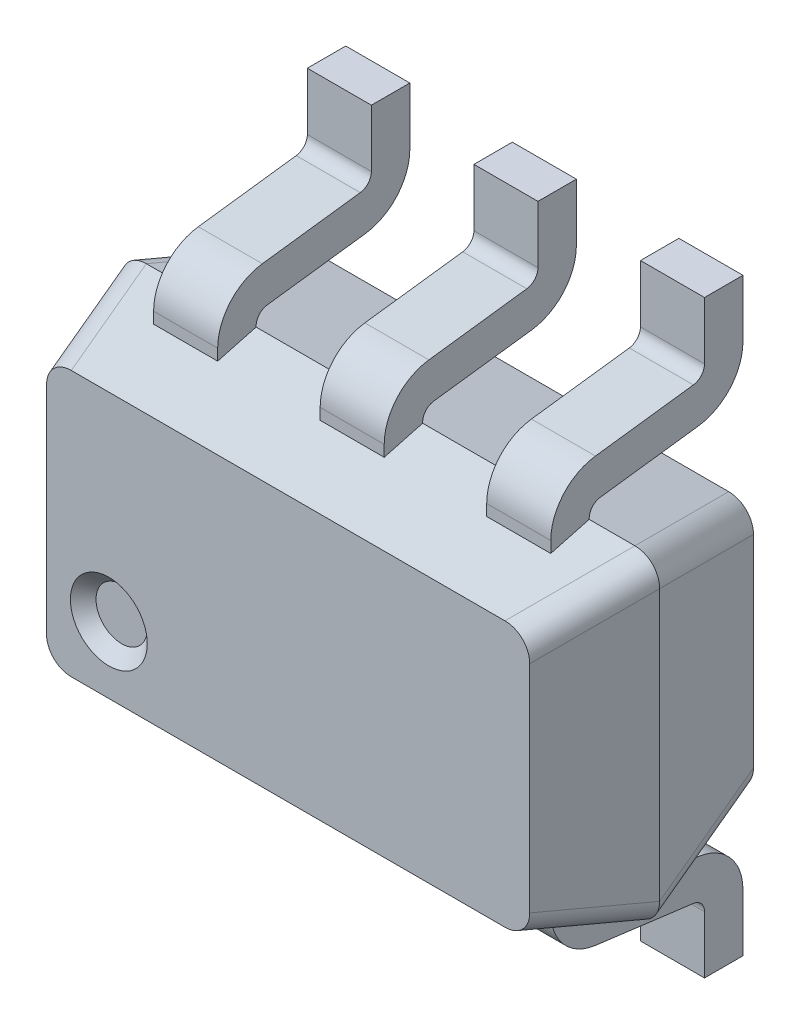
from build123d import *

# Parameters (mm, degrees)
EXTRUDE_START             = 0.6
SKETCH_1_W                = 2.1
SKETCH_1_H                = 1.25
EXTRUDE_1_DEPTH           = 0.4
EXTRUDE_1_TAPER           = 15
EXTRUDE_1_OTHER_WAY_DEPTH = 0.5
EXTRUDE_1_OTHER_WAY_TAPER = 15
EXTRUDE_START_2           = 0.65
EXTRUDE_4_DEPTH           = 0.125
EXTRUDE_5_DEPTH           = 0.125
PATTERN_LINEAR_2_COUNT    = 3
PATTERN_LINEAR_2_PITCH    = 0.65
PATTERN_LINEAR_3_COUNT    = 3
PATTERN_LINEAR_3_PITCH    = 0.65
FILLET_3_R                = 0.1
SKETCH_3_R                = 0.15
CUT_EXTRUDE_6_DEPTH       = 0.05
CUT_EXTRUDE_6_DRAFT       = -45


with BuildPart() as part:
    # Sketch 1 → Extrude 1 (new body)
    with BuildSketch(Plane.XY.offset(EXTRUDE_START)):
        Rectangle(SKETCH_1_W, SKETCH_1_H)
    extrude(amount=EXTRUDE_1_DEPTH, taper=EXTRUDE_1_TAPER)

    # Sketch 1 → Extrude 1 other way (add)
    with BuildSketch(Plane.XY.offset(EXTRUDE_START)):
        Rectangle(SKETCH_1_W, SKETCH_1_H)
    extrude(amount=-EXTRUDE_1_OTHER_WAY_DEPTH, taper=EXTRUDE_1_OTHER_WAY_TAPER)

    # Sketch 2 → Extrude 4 (add, symmetric)
    with BuildSketch(Plane(origin=(0, 0, 0), x_dir=(0, 0, -1), z_dir=(1, 0, 0)).offset(EXTRUDE_START_2)):
        with BuildLine():
            Line((-0.6, 0.55), (-0.75, 0.55))
            Line((-0.75, 0.55), (-0.75, 0.628617172))
            ThreePointArc((-0.75, 0.628617172), (-0.700198025, 0.760679859), (-0.575594468, 0.82697272))
            Line((-0.575594468, 0.82697272), (-0.193601383, 0.876262542))
            ThreePointArc((-0.193601383, 0.876262542), (-0.162450494, 0.892835757), (-0.15, 0.925851429))
            Line((-0.15, 0.925851429), (-0.15, 1.15))
            Line((-0.15, 1.15), (0, 1.15))
            Line((0, 1.15), (0, 0.925851429))
            ThreePointArc((0, 0.925851429), (-0.049801975, 0.793788742), (-0.174405532, 0.727495881))
            Line((-0.174405532, 0.727495881), (-0.556398617, 0.678206059))
            ThreePointArc((-0.556398617, 0.678206059), (-0.587549506, 0.661632844), (-0.6, 0.628617172))
            Line((-0.6, 0.628617172), (-0.6, 0.55))
        make_face()
    extrude_4 = extrude(amount=EXTRUDE_4_DEPTH, both=True)

    # Sketch 2_4 → Extrude 5 (add, symmetric)
    with BuildSketch(Plane(origin=(0, 0, 0), x_dir=(0, 0, -1), z_dir=(1, 0, 0)).offset(EXTRUDE_START_2)):
        with BuildLine():
            ThreePointArc((-0.6, -0.628617172), (-0.587549506, -0.661632844), (-0.556398617, -0.678206059))
            Line((-0.556398617, -0.678206059), (-0.174405532, -0.727495881))
            ThreePointArc((-0.174405532, -0.727495881), (-0.049801975, -0.793788742), (0, -0.925851429))
            Line((0, -0.925851429), (0, -1.15))
            Line((0, -1.15), (-0.15, -1.15))
            Line((-0.15, -1.15), (-0.15, -0.925851429))
            ThreePointArc((-0.15, -0.925851429), (-0.162450494, -0.892835757), (-0.193601383, -0.876262542))
            Line((-0.193601383, -0.876262542), (-0.575594468, -0.82697272))
            ThreePointArc((-0.575594468, -0.82697272), (-0.700198025, -0.760679859), (-0.75, -0.628617172))
            Line((-0.75, -0.628617172), (-0.75, -0.55))
            Line((-0.75, -0.55), (-0.6, -0.55))
            Line((-0.6, -0.55), (-0.6, -0.628617172))
        make_face()
    extrude_5 = extrude(amount=EXTRUDE_5_DEPTH, both=True)

    # Pattern Linear 2: Extrude 5 ×3
    with Locations(*[(-i * PATTERN_LINEAR_2_PITCH, 0, 0) for i in range(1, PATTERN_LINEAR_2_COUNT)]):
        add(extrude_5)

    # Pattern Linear 3: Extrude 4 ×3
    with Locations(*[(-i * PATTERN_LINEAR_3_PITCH, 0, 0) for i in range(1, PATTERN_LINEAR_3_COUNT)]):
        add(extrude_4)

    # Fillet 3
    fillet_3_edges = [part.edges().sort_by_distance(p)[0] for p in [
        (0.996410162, -0.571410162, 0.8),
        (0.996410162, 0.571410162, 0.8),
        (-0.996410162, 0.571410162, 0.8),
        (-0.996410162, -0.571410162, 0.8),
        (0.983012702, -0.558012702, 0.35),
        (-0.983012702, -0.558012702, 0.35),
        (-0.983012702, 0.558012702, 0.35),
        (0.983012702, 0.558012702, 0.35),
    ]]
    fillet(fillet_3_edges, radius=FILLET_3_R)


with BuildPart() as cut_extrude_6_tool:
    # Sketch 3 → Cut-Extrude 6 (with draft: the straight prism first)
    with BuildSketch(Plane.XY.offset(1)):
        with Locations((-0.69974874, -0.257664746)):
            Circle(SKETCH_3_R)
    extrude(amount=-CUT_EXTRUDE_6_DEPTH)
    # Cut-Extrude 6: the draft: its side faces are tilted about the plane it starts from
    cut_extrude_6_sides = [cut_extrude_6_tool.faces().sort_by_distance(p)[0] for p in [
        (-0.84974874, -0.257664746, 0.975),
    ]]
    draft(cut_extrude_6_sides, Plane.XY.offset(1), CUT_EXTRUDE_6_DRAFT)


with BuildPart() as part_1:
    add(part.part)

    # Cut-Extrude 6: cut by cut_extrude_6_tool
    add(cut_extrude_6_tool.part, mode=Mode.SUBTRACT)


solid = part_1.part
